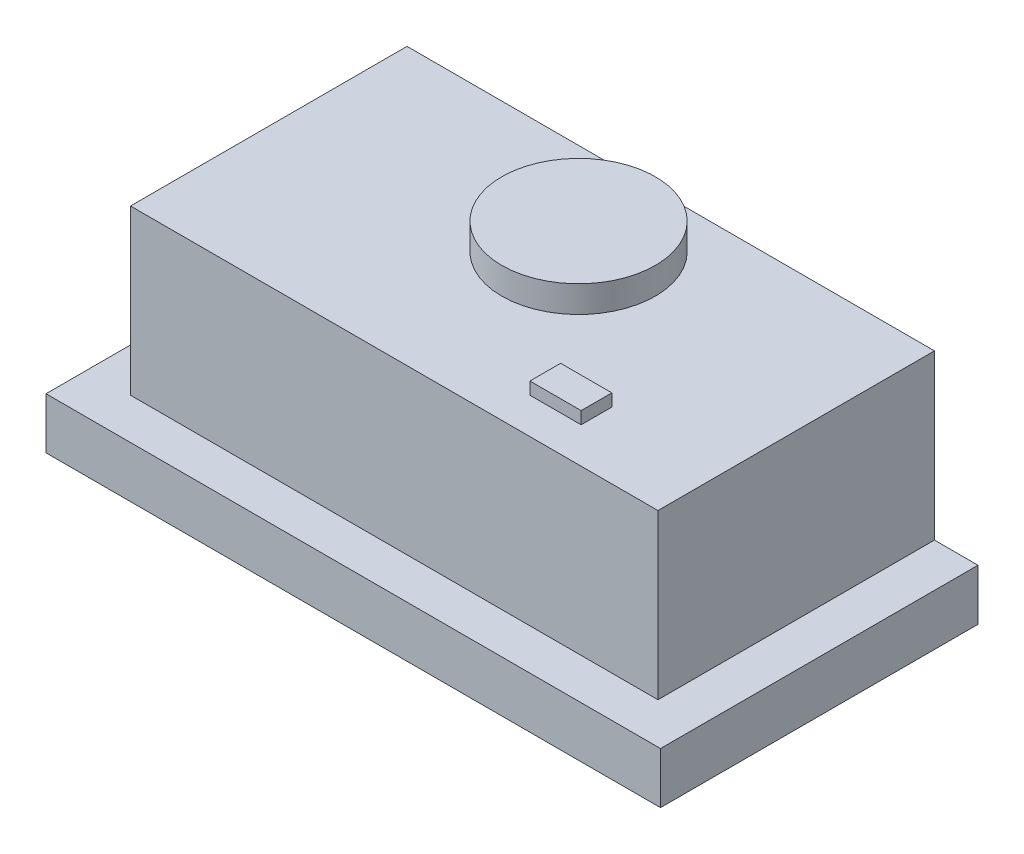
from build123d import *

# Parameters (mm, degrees)
SKETCH1_W           = 600
SKETCH1_H           = 310
BOSS_EXTRUDE1_DEPTH = 50
SKETCH2_W           = 515
SKETCH2_H           = 270
BOSS_EXTRUDE2_DEPTH = 160
SKETCH3_R           = 75
BOSS_EXTRUDE3_DEPTH = 26
SKETCH4_W           = 30
SKETCH4_H           = 12
BOSS_EXTRUDE4_DEPTH = 50


with BuildPart() as part:
    # Sketch1 → Boss-Extrude1 (new body)
    with BuildSketch(Plane(origin=(0, 0, 0), x_dir=(1, 0, 0), z_dir=(0, 1, 0))):
        Rectangle(SKETCH1_W, SKETCH1_H)
    extrude(amount=BOSS_EXTRUDE1_DEPTH)

    # Sketch2 → Boss-Extrude2 (add)
    with BuildSketch(Plane(origin=(0, 50, 0), x_dir=(1, 0, 0), z_dir=(0, 1, 0))):
        with Locations((0, 20)):
            Rectangle(SKETCH2_W, SKETCH2_H)
    extrude(amount=BOSS_EXTRUDE2_DEPTH)

    # Sketch3 → Boss-Extrude3 (add)
    with BuildSketch(Plane(origin=(0, 210, 0), x_dir=(1, 0, 0), z_dir=(0, 1, 0))):
        with Locations((0, 65)):
            Circle(SKETCH3_R)
    extrude(amount=BOSS_EXTRUDE3_DEPTH)

    # Sketch4 → Boss-Extrude4 (add)
    with BuildSketch(Plane(origin=(147.5, 0, 0), x_dir=(0, 0, -1), z_dir=(1, 0, 0))):
        with Locations((-65, 216)):
            Rectangle(SKETCH4_W, SKETCH4_H)
    extrude(amount=-BOSS_EXTRUDE4_DEPTH)


solid = part.part
